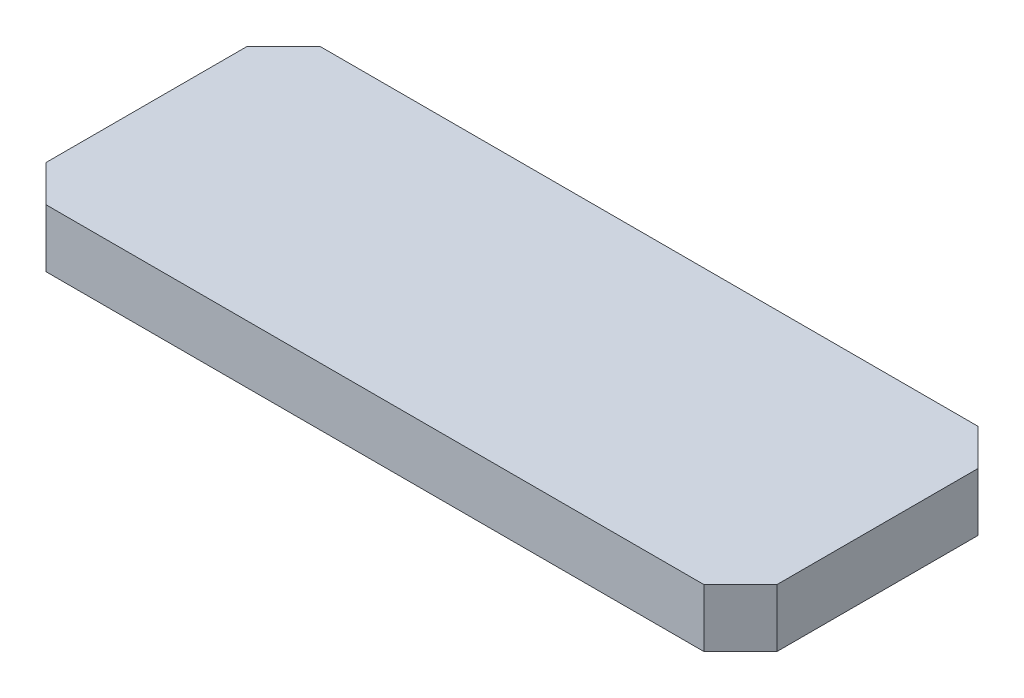
from build123d import *

# Parameters (mm, degrees)
SKETCH1_W           = 40
SKETCH1_H           = 15
BOSS_EXTRUDE1_DEPTH = 3.175
CHAMFER1_SIZE       = 2


with BuildPart() as part:
    # Sketch1 → Boss-Extrude1 (new body)
    with BuildSketch(Plane(origin=(0, 0, 0), x_dir=(1, 0, 0), z_dir=(0, 1, 0))):
        with Locations((20, 7.5)):
            Rectangle(SKETCH1_W, SKETCH1_H)
    extrude(amount=BOSS_EXTRUDE1_DEPTH)

    # Chamfer1
    chamfer1_edges = [part.edges().sort_by_distance(p)[0] for p in [
        (0, 1.5875, -15),
        (40, 1.5875, -15),
        (40, 1.5875, 0),
        (0, 1.5875, 0),
    ]]
    chamfer(chamfer1_edges, length=CHAMFER1_SIZE)


solid = part.part
